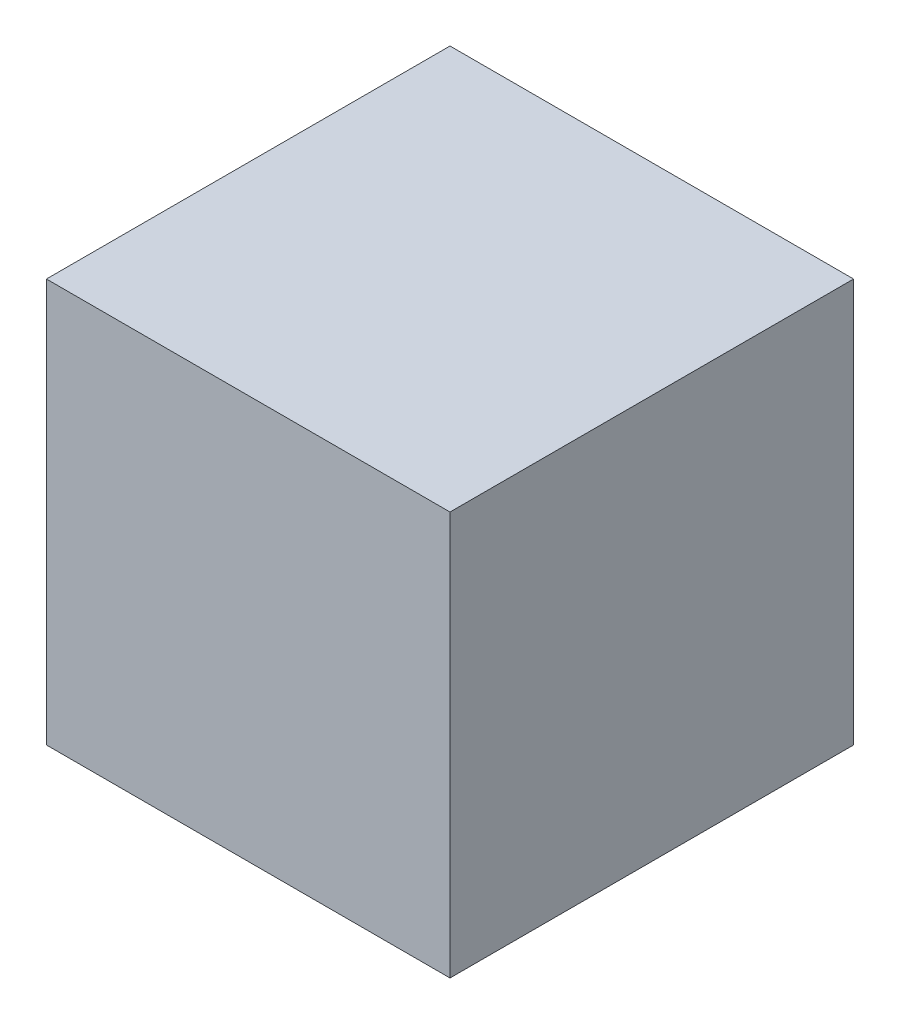
from build123d import *

# Parameters (mm, degrees)
SKETCH1_W           = 14
SKETCH1_H           = 14
BOSS_EXTRUDE1_DEPTH = 14


with BuildPart() as part:
    # Sketch1 → Boss-Extrude1 (new body)
    with BuildSketch(Plane(origin=(0, 0, 0), x_dir=(1, 0, 0), z_dir=(0, 1, 0))):
        with Locations((7, -7)):
            Rectangle(SKETCH1_W, SKETCH1_H)
    extrude(amount=BOSS_EXTRUDE1_DEPTH)


solid = part.part
